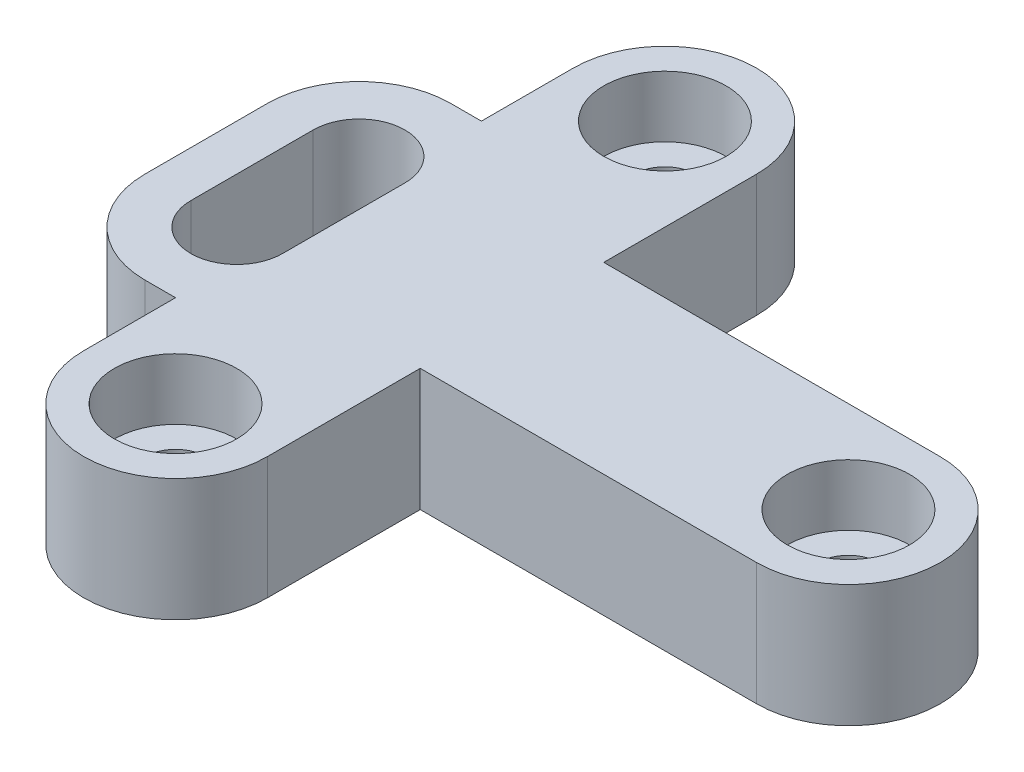
from build123d import *

# Parameters (mm, degrees)
BOSS_EXTRUDE2_DEPTH = 10
SKETCH3_R           = 10
CUT_EXTRUDE1_DEPTH  = 10
SKETCH4_R           = 5
CUT_EXTRUDE2_DEPTH  = 21


with BuildPart() as part:
    # Sketch2 → Boss-Extrude2 (new body, symmetric)
    with BuildSketch(Plane(origin=(0, 0, 0), x_dir=(1, 0, 0), z_dir=(0, 1, 0))):
        with BuildLine():
            Line((5, -30), (5, -15))
            Line((5, -15), (0, -15))
            ThreePointArc((0, -15), (-10.606601718, -10.606601718), (-15, 0))
            Line((-15, 0), (-15, 20))
            ThreePointArc((-15, 20), (-10.606601718, 30.606601718), (0, 35))
            Line((0, 35), (5, 35))
            Line((5, 35), (5, 50))
            ThreePointArc((5, 50), (20, 65), (35, 50))
            Line((35, 50), (35, 25))
            Line((35, 25), (90, 25))
            ThreePointArc((90, 25), (105, 10), (90, -5))
            Line((90, -5), (35, -5))
            Line((35, -5), (35, -30))
            ThreePointArc((35, -30), (20, -45), (5, -30))
        make_face()
        with BuildLine():
            Line((7.5, 20), (7.5, 0))
            ThreePointArc((7.5, 0), (0, -7.5), (-7.5, 0))
            Line((-7.5, 0), (-7.5, 20))
            ThreePointArc((-7.5, 20), (0, 27.5), (7.5, 20))
        make_face(mode=Mode.SUBTRACT)
    extrude(amount=BOSS_EXTRUDE2_DEPTH, both=True)

    # Sketch3 → Cut-Extrude1 (cut)
    with BuildSketch(Plane(origin=(0, 10, 0), x_dir=(1, 0, 0), z_dir=(0, 1, 0))):
        with Locations((90, 10)):
            Circle(SKETCH3_R)
        with Locations((20, 50)):
            Circle(SKETCH3_R)
        with Locations((20, -30)):
            Circle(SKETCH3_R)
    extrude(amount=-CUT_EXTRUDE1_DEPTH, mode=Mode.SUBTRACT)

    # Sketch4 → Cut-Extrude2 (cut, through all)
    with BuildSketch(Plane(origin=(0, 10, 0), x_dir=(1, 0, 0), z_dir=(0, 1, 0))):
        with Locations((20, 50)):
            Circle(SKETCH4_R)
        with Locations((20, -30)):
            Circle(SKETCH4_R)
        with Locations((90, 10)):
            Circle(SKETCH4_R)
    extrude(amount=-CUT_EXTRUDE2_DEPTH, mode=Mode.SUBTRACT)


solid = part.part
